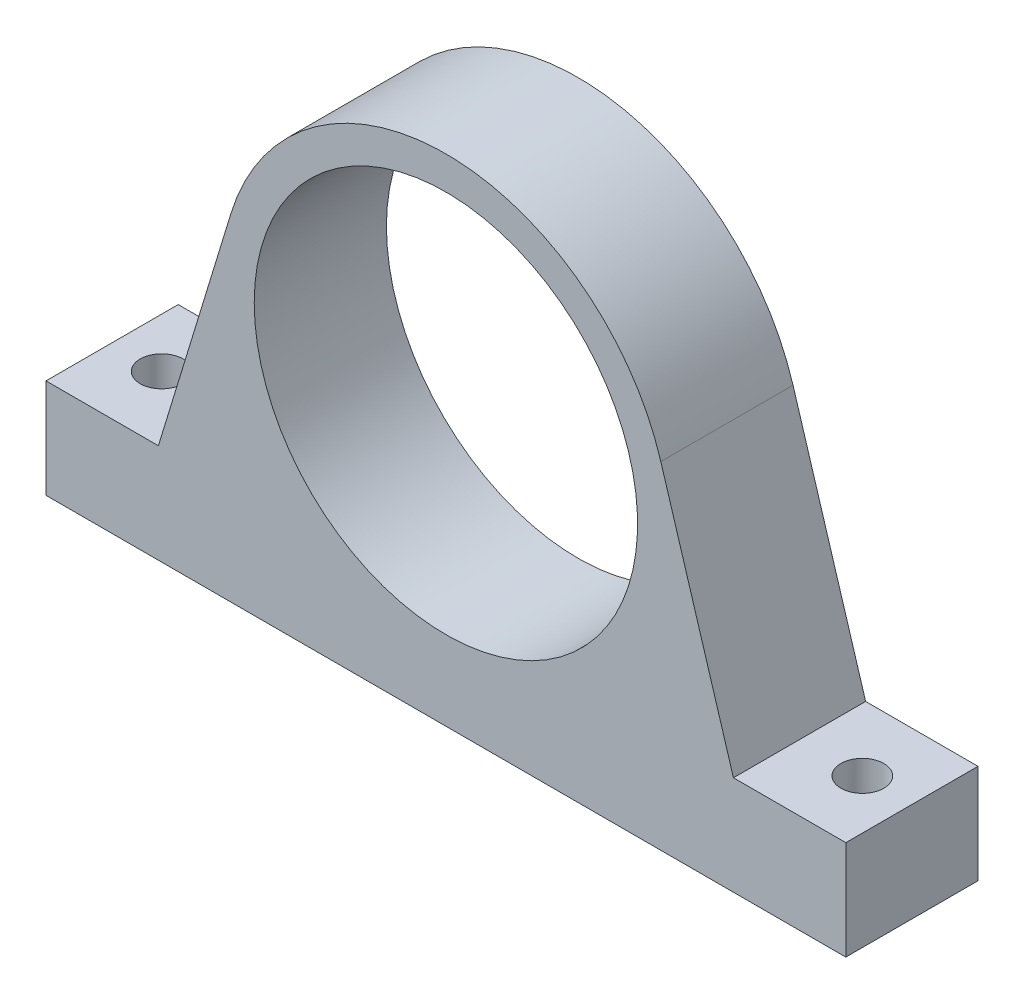
from build123d import *

# Parameters (mm, degrees)
BOSS_EXTRUDE1_DEPTH     = 20
SKETCH2_R               = 29
CUT_EXTRUDE1_DEPTH      = 1
CUT_EXTRUDE1_DEPTH_BACK = 21
CUT_EXTRUDE2_START      = -16
SKETCH3_R               = 3.25
CUT_EXTRUDE2_DEPTH      = 77


with BuildPart() as part:
    # Sketch1 → Boss-Extrude1 (new body)
    with BuildSketch(Plane.XY):
        with BuildLine():
            Line((-60.5, 0), (60.5, 0))
            Line((60.5, 0), (60.5, 15))
            Line((60.5, 15), (43.5, 15))
            Line((43.5, 15), (32.514998433, 50.938555071))
            ThreePointArc((32.514998433, 50.938555071), (0, 75), (-32.514998433, 50.938555071))
            Line((-32.514998433, 50.938555071), (-43.5, 15))
            Line((-43.5, 15), (-60.5, 15))
            Line((-60.5, 15), (-60.5, 0))
        make_face()
    extrude(amount=BOSS_EXTRUDE1_DEPTH)

    # Sketch2 → Cut-Extrude1 (cut, two sides)
    with BuildSketch(Plane(origin=(0, 0, 0), x_dir=(-1, 0, 0), z_dir=(0, 0, -1))) as cut_extrude1_sk:
        with Locations((0, 41)):
            Circle(SKETCH2_R)
    extrude(amount=CUT_EXTRUDE1_DEPTH, mode=Mode.SUBTRACT)
    extrude(cut_extrude1_sk.sketch, amount=-CUT_EXTRUDE1_DEPTH_BACK, mode=Mode.SUBTRACT)

    # Sketch3 → Cut-Extrude2 (cut)
    with BuildSketch(Plane(origin=(0, 15, 0), x_dir=(1, 0, 0), z_dir=(0, 1, 0)).offset(CUT_EXTRUDE2_START)):
        with Locations((-53, -10)):
            Circle(SKETCH3_R)
    cut_extrude2 = extrude(amount=CUT_EXTRUDE2_DEPTH, mode=Mode.SUBTRACT)

    # Mirror1: Cut-Extrude2 across plane
    add(cut_extrude2.mirror(Plane(origin=(0, 0, 0), x_dir=(0, 0, 1), z_dir=(1, 0, 0))), mode=Mode.SUBTRACT)


solid = part.part
